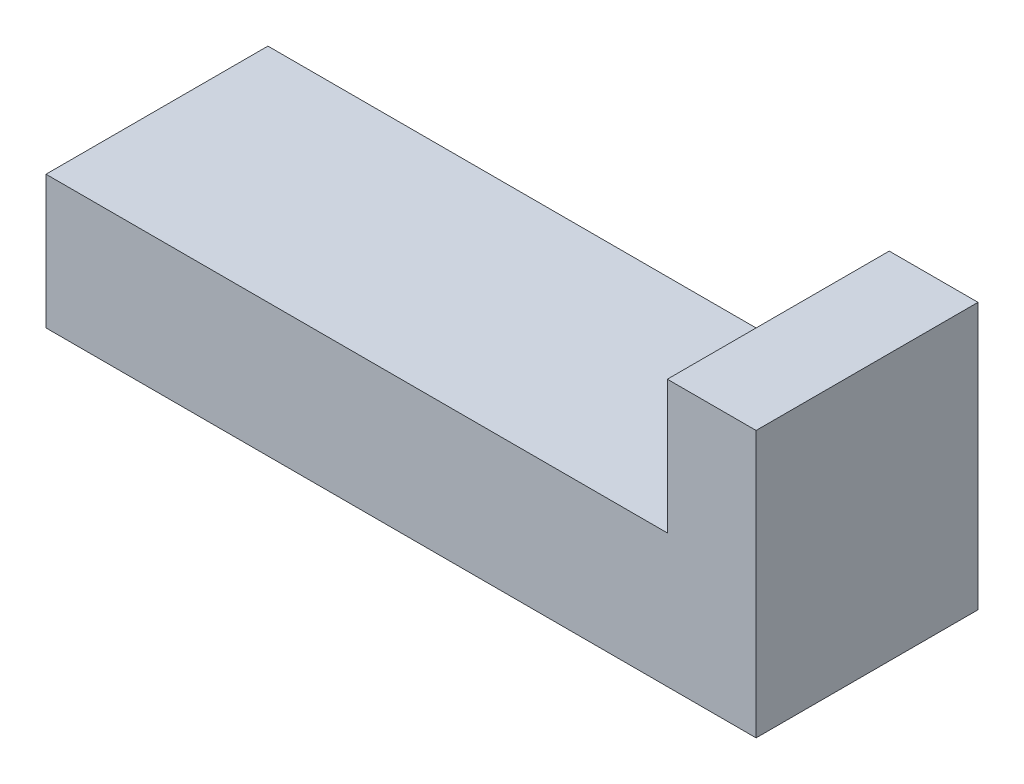
from build123d import *

# Parameters (mm, degrees)
BOSS_EXTRUDE1_DEPTH = 5


with BuildPart() as part:
    # Sketch1 → Boss-Extrude1 (new body)
    with BuildSketch(Plane.XY):
        Polygon((0, 0), (16, 0), (16, 6), (14, 6), (14, 3), (0, 3), align=None)
    extrude(amount=BOSS_EXTRUDE1_DEPTH)


solid = part.part
